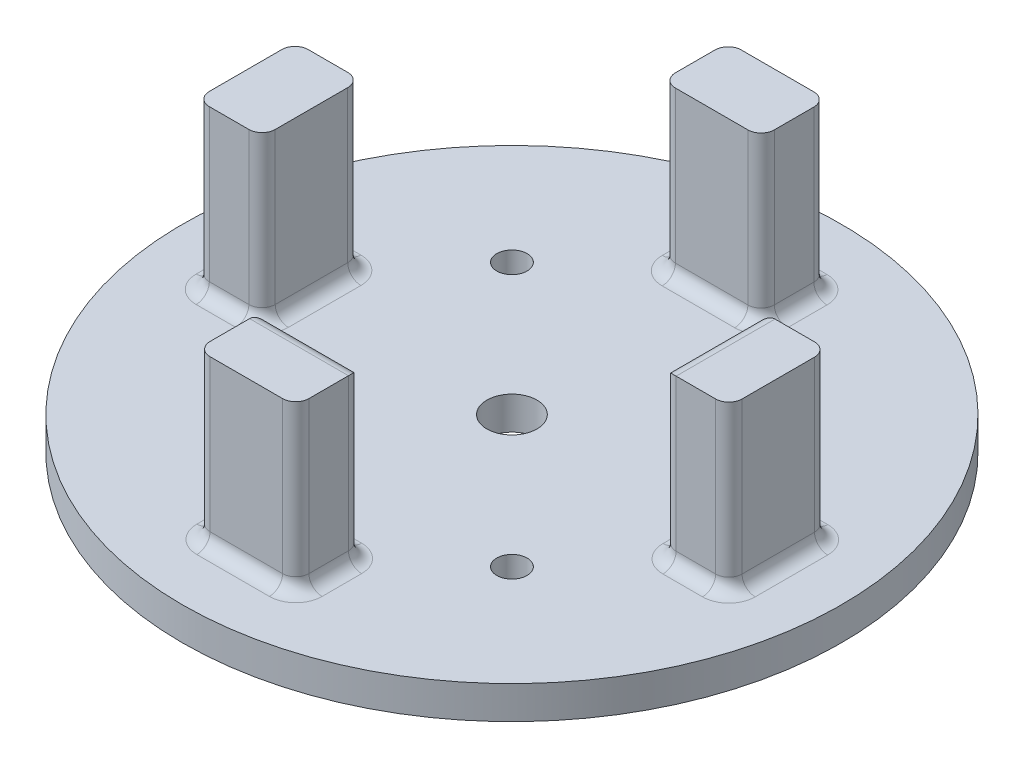
from build123d import *

# Parameters (mm, degrees)
SKETCH2_R           = 63.5
SKETCH2_R_2         = 2.921
SKETCH2_R_3         = 4.826
BOSS_EXTRUDE2_DEPTH = 6.35
SKETCH3_W           = 19.05
SKETCH3_H           = 12.7
SKETCH3_W_2         = 12.7
SKETCH3_H_2         = 19.05
BOSS_EXTRUDE3_DEPTH = 31.75
FILLET1_R           = 2.54


with BuildPart() as part:
    # Sketch2 → Boss-Extrude2 (new body)
    with BuildSketch(Plane(origin=(0, 0, 0), x_dir=(1, 0, 0), z_dir=(0, 1, 0))):
        Circle(SKETCH2_R)
        with Locations((-25.4, 25.4)):
            Circle(SKETCH2_R_2, mode=Mode.SUBTRACT)
        with Locations((25.4, 25.4)):
            Circle(SKETCH2_R_2, mode=Mode.SUBTRACT)
        with Locations((25.4, -25.4)):
            Circle(SKETCH2_R_2, mode=Mode.SUBTRACT)
        with Locations((-25.4, -25.4)):
            Circle(SKETCH2_R_2, mode=Mode.SUBTRACT)
        Circle(SKETCH2_R_3, mode=Mode.SUBTRACT)
    extrude(amount=BOSS_EXTRUDE2_DEPTH)

    # Sketch3 → Boss-Extrude3 (add)
    with BuildSketch(Plane(origin=(0, 6.35, 0), x_dir=(1, 0, 0), z_dir=(0, 1, 0))):
        with Locations((0, 44.831)):
            Rectangle(SKETCH3_W, SKETCH3_H)
        with Locations((0, -44.831)):
            Rectangle(SKETCH3_W, SKETCH3_H)
        with Locations((-44.971451378, 0)):
            Rectangle(SKETCH3_W_2, SKETCH3_H_2)
        with Locations((44.971451378, 0)):
            Rectangle(SKETCH3_W_2, SKETCH3_H_2)
    extrude(amount=BOSS_EXTRUDE3_DEPTH)

    # Fillet1
    fillet1_edges = [part.edges().sort_by_distance(p)[0] for p in [
        (9.525, 6.35, -44.831),
        (9.525, 22.225, -38.481),
        (0, 6.35, -51.181),
        (9.525, 22.225, -51.181),
        (-9.525, 6.35, -44.831),
        (-9.525, 22.225, -51.181),
        (0, 6.35, -38.481),
        (-9.525, 22.225, -38.481),
        (-9.525, 6.35, 44.831),
        (-9.525, 22.225, 38.481),
        (0, 6.35, 51.181),
        (-9.525, 22.225, 51.181),
        (9.525, 6.35, 44.831),
        (9.525, 22.225, 51.181),
        (0, 6.35, 38.481),
        (9.525, 22.225, 38.481),
        (0, 38.1, 38.481),
        (-38.621451378, 6.35, 0),
        (-38.621451378, 22.225, 9.525),
        (-44.971451378, 6.35, -9.525),
        (-38.621451378, 22.225, -9.525),
        (-51.321451378, 6.35, 0),
        (-51.321451378, 22.225, -9.525),
        (-44.971451378, 6.35, 9.525),
        (-51.321451378, 22.225, 9.525),
        (44.971451378, 6.35, -9.525),
        (51.321451378, 22.225, -9.525),
        (38.621451378, 6.35, 0),
        (38.621451378, 22.225, -9.525),
        (44.971451378, 6.35, 9.525),
        (38.621451378, 22.225, 9.525),
        (51.321451378, 6.35, 0),
        (51.321451378, 22.225, 9.525),
        (38.621451378, 38.1, 0),
    ]]
    fillet(fillet1_edges, radius=FILLET1_R)


solid = part.part
